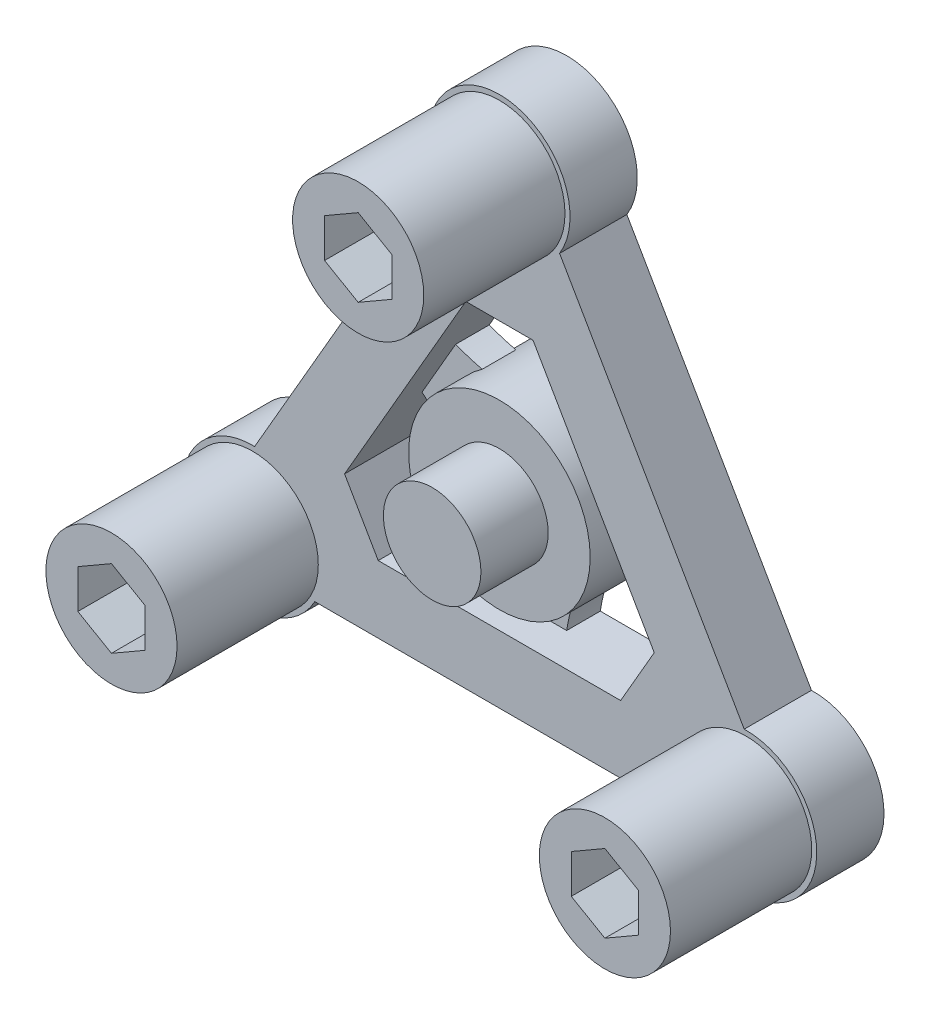
from build123d import *

# Parameters (mm, degrees)
BOSS_EXTRUDE1_DEPTH = 5
BOSS_EXTRUDE2_DEPTH = 5
SKETCH4_R           = 9.75
BOSS_EXTRUDE3_DEPTH = 21
BOSS_EXTRUDE4_START = -15
SKETCH5_R           = 13.5
BOSS_EXTRUDE4_DEPTH = 20
SKETCH5_3_R         = 7.25
BOSS_EXTRUDE5_DEPTH = 15
CHAMFER1_SIZE       = 10
CUT_EXTRUDE1_DEPTH  = 10
SKETCH9_R           = 10.15
CUT_EXTRUDE2_DEPTH  = 10
CHAMFER2_SIZE       = 1
SKETCH10_R          = 1.65
CUT_EXTRUDE3_DEPTH  = 32.6785
CIRPATTERN1_COUNT   = 2
CIRPATTERN1_ANGLE   = 90


with BuildPart() as part:
    # Sketch2 → Boss-Extrude1 (new body, symmetric)
    with BuildSketch(Plane.XY):
        with BuildLine():
            ThreePointArc((8.946673347, 36.860907204), (0, 52.857), (-8.946673347, 36.860907204))
            Line((-8.946673347, 36.860907204), (-36.395818719, -10.682407204))
            ThreePointArc((-36.395818719, -10.682407204), (-45.775504768, -26.4285), (-27.449145372, -26.1785))
            Line((-27.449145372, -26.1785), (27.449145372, -26.1785))
            ThreePointArc((27.449145372, -26.1785), (45.775504768, -26.4285), (36.395818719, -10.682407204))
            Line((36.395818719, -10.682407204), (8.946673347, 36.860907204))
        make_face()
        Polygon((-28.02198399, -16.1785), (0, 32.357), (28.02198399, -16.1785), align=None, mode=Mode.SUBTRACT)
    extrude(amount=BOSS_EXTRUDE1_DEPTH, both=True)

    # Sketch3 → Boss-Extrude2 (add)
    with BuildSketch(Plane.XY):
        with BuildLine():
            Line((-16.510991995, 3.759122981), (-11.510991995, 12.419377019))
            ThreePointArc((-11.510991995, 12.419377019), (0, 10.282645658), (11.510991995, 12.419377019))
            Line((11.510991995, 12.419377019), (16.510991995, 3.759122981))
            ThreePointArc((16.510991995, 3.759122981), (8.905032358, -5.141322829), (5, -16.1785))
            Line((5, -16.1785), (-5, -16.1785))
            ThreePointArc((-5, -16.1785), (-8.905032358, -5.141322829), (-16.510991995, 3.759122981))
        make_face()
    extrude(amount=-BOSS_EXTRUDE2_DEPTH)

    # Sketch4 → Boss-Extrude3 (add)
    with BuildSketch(Plane.XY.offset(5)):
        with Locations((-36.682238028, -21.1785)):
            Circle(SKETCH4_R)
        with Locations((36.682238028, -21.1785)):
            Circle(SKETCH4_R)
        with Locations((0, 42.357)):
            Circle(SKETCH4_R)
    extrude(amount=BOSS_EXTRUDE3_DEPTH)

    # Sketch5 → Boss-Extrude4 (add)
    with BuildSketch(Plane.XY.offset(BOSS_EXTRUDE4_START)):
        Circle(SKETCH5_R)
    extrude(amount=BOSS_EXTRUDE4_DEPTH)

    # Sketch5_3 → Boss-Extrude5 (add)
    with BuildSketch(Plane.XY):
        Circle(SKETCH5_3_R)
    extrude(amount=BOSS_EXTRUDE5_DEPTH)

    # Chamfer1
    chamfer1_edges = [part.edges().sort_by_distance(p)[0] for p in [
        (28.02198399, -16.1785, 0),
        (-28.02198399, -16.1785, 0),
        (0, 32.357, 0),
    ]]
    chamfer(chamfer1_edges, length=CHAMFER1_SIZE)

    # Sketch8 → Cut-Extrude1 (cut)
    with BuildSketch(Plane.XY.offset(26)):
        Polygon((-41.682238028, -24.065251346), (-36.682238028, -26.952002692), (-31.682238028, -24.065251346), (-31.682238028, -18.291748654), (-36.682238028, -15.404997308), (-41.682238028, -18.291748654), align=None)
        Polygon((41.682238028, -24.065251346), (41.682238028, -18.291748654), (36.682238028, -15.404997308), (31.682238028, -18.291748654), (31.682238028, -24.065251346), (36.682238028, -26.952002692), align=None)
        Polygon((0, 48.130502692), (-5, 45.243751346), (-5, 39.470248654), (0, 36.583497308), (5, 39.470248654), (5, 45.243751346), align=None)
    extrude(amount=-CUT_EXTRUDE1_DEPTH, mode=Mode.SUBTRACT)

    # Sketch9 → Cut-Extrude2 (cut)
    with BuildSketch(Plane(origin=(0, 0, -15), x_dir=(-1, 0, 0), z_dir=(0, 0, -1))):
        Circle(SKETCH9_R)
    extrude(amount=-CUT_EXTRUDE2_DEPTH, mode=Mode.SUBTRACT)

    # Chamfer2
    chamfer2_edges = [part.edges().sort_by_distance(p)[0] for p in [
        (10.15, 0, -15),
        (-13.5, 0, -15),
    ]]
    chamfer(chamfer2_edges, length=CHAMFER2_SIZE)

    # Sketch10 → Cut-Extrude3 (cut, through all)
    with BuildSketch(Plane(origin=(0, 0, 0), x_dir=(1, 0, 0), z_dir=(0, 1, 0))):
        with Locations((0, 10)):
            Circle(SKETCH10_R)
    cut_extrude3 = extrude(amount=-CUT_EXTRUDE3_DEPTH, mode=Mode.SUBTRACT)

    # CirPattern1: Cut-Extrude3 ×2 about axis
    cirpattern1_axis = Axis((0, 0, 43.183766184), (0, 0, -1))
    for i in range(1, CIRPATTERN1_COUNT):
        add(cut_extrude3.rotate(cirpattern1_axis, i * CIRPATTERN1_ANGLE / (CIRPATTERN1_COUNT - 1)), mode=Mode.SUBTRACT)


solid = part.part
